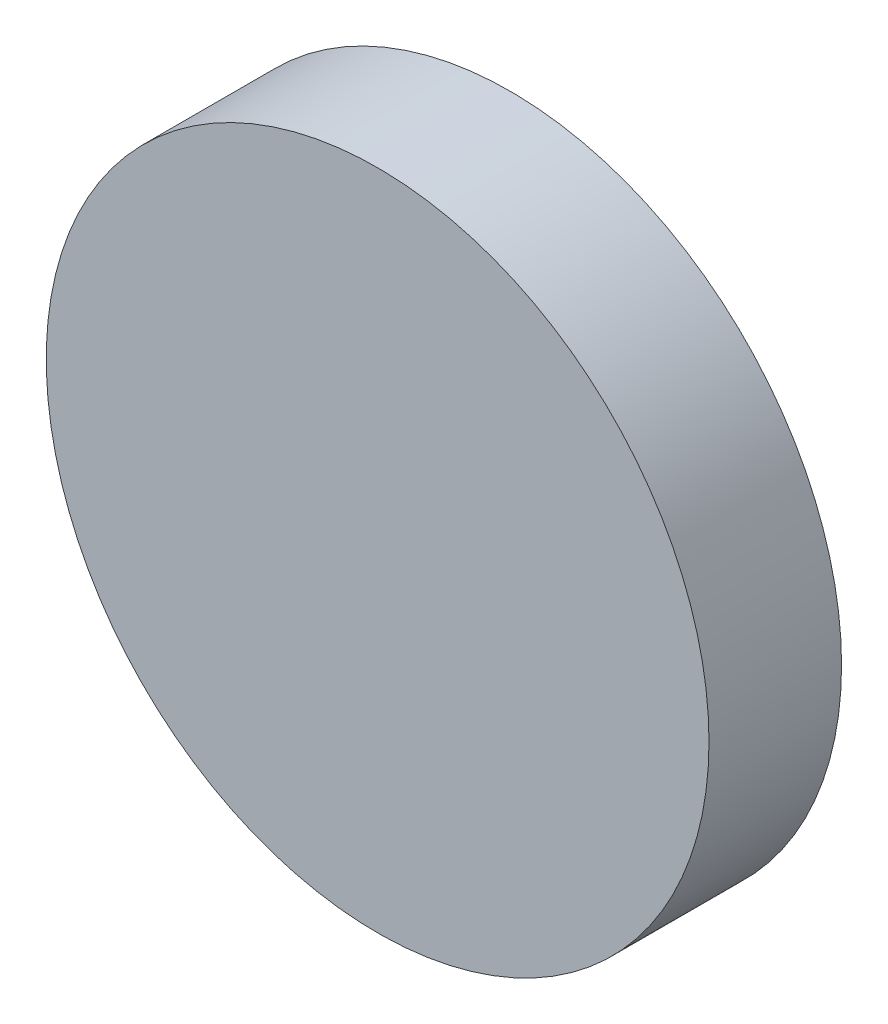
from build123d import *

# Parameters (mm, degrees)
SKETCH_1_R      = 10
EXTRUDE_1_DEPTH = 4


with BuildPart() as part:
    # 草图1 → 凸台-拉伸1 (new body)
    with BuildSketch(Plane.XY):
        Circle(SKETCH_1_R)
    extrude(amount=EXTRUDE_1_DEPTH)


solid = part.part
